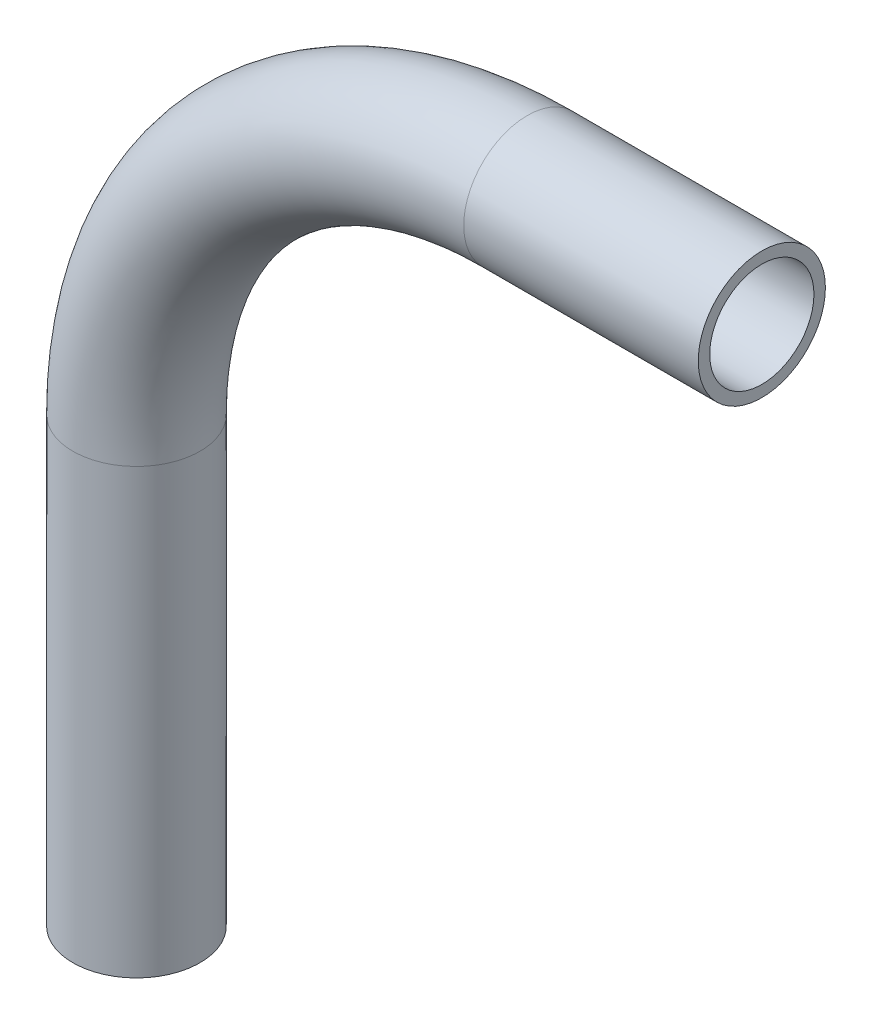
from build123d import *

# Parameters (mm, degrees)
SKETCH2_R   = 3.8735
SKETCH2_R_2 = 3.175


with BuildPart() as part:
    # Sweep1: sweep along a path in Sketch1
    with BuildLine(Plane.XY) as sweep1_path:
        Line((0, -50.8), (0, -23.8125))
        ThreePointArc((0, -23.8125), (6.974519773, -6.974519773), (23.8125, 0))
        Line((23.8125, 0), (38.1, 0))
    # Sketch2 → Sweep1 (sweep)
    with BuildSketch(Plane(origin=(38.1, 0, 0), x_dir=(0, 0, -1), z_dir=(1, 0, 0))):
        Circle(SKETCH2_R)
        Circle(SKETCH2_R_2, mode=Mode.SUBTRACT)
    sweep(path=sweep1_path.line)


solid = part.part
